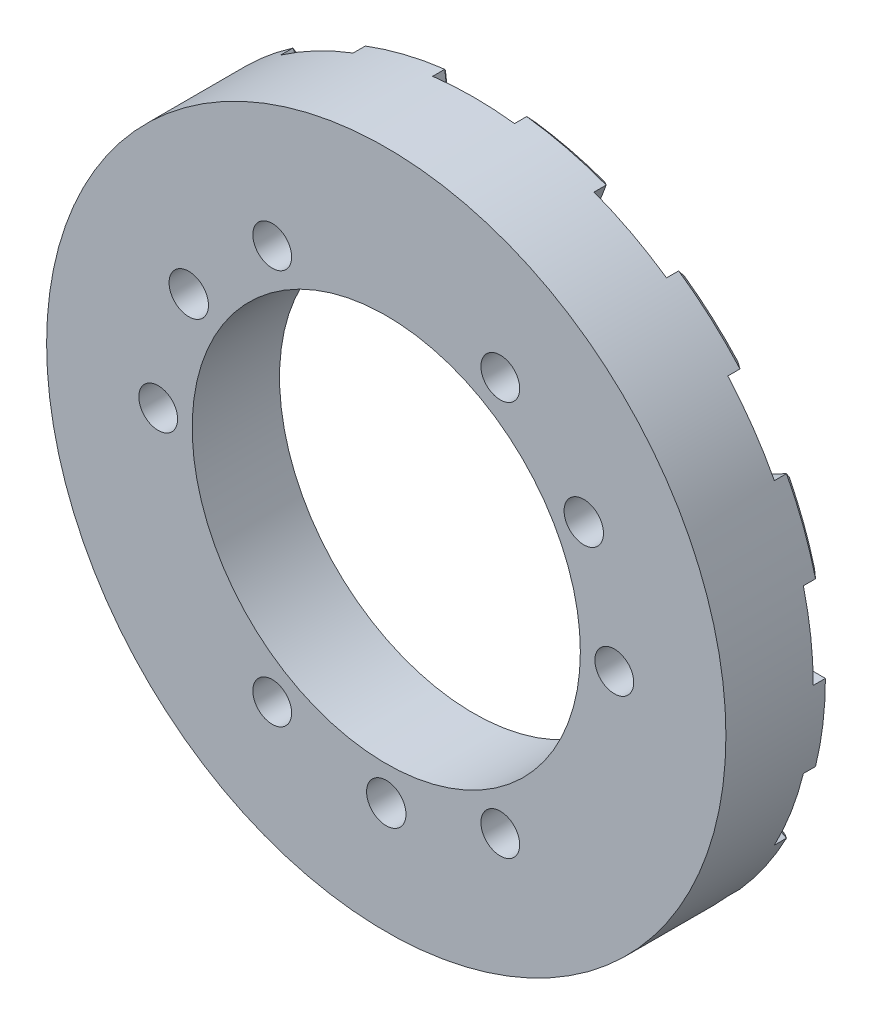
from build123d import *

# Parameters (mm, degrees)
SKETCH_1_R               = 70
SKETCH_1_R_2             = 40
EXTRUDE_1_DEPTH          = 18
SKETCH_2_R               = 4
CUT_EXTRUDE_1_DEPTH      = 20
PATTERN_CIRCULAR_1_COUNT = 6
SKETCH_3_R               = 4.06
CUT_EXTRUDE_2_DEPTH      = 20
PATTERN_CIRCULAR_2_COUNT = 3
EXTRUDE_2_DEPTH          = 3.5
CHAMFER_1_SIZE           = 1


with BuildPart() as part:
    # 草图1 → 凸台-拉伸1 (new body)
    with BuildSketch(Plane.XY):
        Circle(SKETCH_1_R)
        Circle(SKETCH_1_R_2, mode=Mode.SUBTRACT)
    extrude(amount=EXTRUDE_1_DEPTH)

    # 草图2 → 切除-拉伸1 (cut)
    with BuildSketch(Plane.XY.offset(18)):
        with Locations((47, 0)):
            Circle(SKETCH_2_R)
    cut_extrude_1 = extrude(amount=-CUT_EXTRUDE_1_DEPTH, mode=Mode.SUBTRACT)

    # 阵列(圆周)1: 切除-拉伸1 ×6 about axis
    pattern_circular_1_axis = Axis((0, 0, 0), (0, 0, 1))
    for i in range(1, PATTERN_CIRCULAR_1_COUNT):
        add(cut_extrude_1.rotate(pattern_circular_1_axis, i * 360 / PATTERN_CIRCULAR_1_COUNT), mode=Mode.SUBTRACT)

    # 草图3 → 切除-拉伸2 (cut)
    with BuildSketch(Plane.XY.offset(18)):
        with Locations((40.703193978, 23.5)):
            Circle(SKETCH_3_R)
    cut_extrude_2 = extrude(amount=-CUT_EXTRUDE_2_DEPTH, mode=Mode.SUBTRACT)

    # 阵列(圆周)2: 切除-拉伸2 ×3 about axis
    pattern_circular_2_axis = Axis((0, 0, 0), (0, 0, 1))
    for i in range(1, PATTERN_CIRCULAR_2_COUNT):
        add(cut_extrude_2.rotate(pattern_circular_2_axis, i * 360 / PATTERN_CIRCULAR_2_COUNT), mode=Mode.SUBTRACT)

    # 草图4 → 凸台-拉伸2 (add)
    with BuildSketch(Plane(origin=(0, 0, 0), x_dir=(-1, 0, 0), z_dir=(0, 0, -1))):
        with BuildLine():
            Line((60, 0), (70, 0))
            ThreePointArc((70, 0), (69.489621187, -8.437567618), (67.96592722, -16.7520965))
            Line((67.96592722, -16.7520965), (58.256509046, -14.358939857))
            ThreePointArc((58.256509046, -14.358939857), (59.562532446, -7.232200815), (60, 0))
        make_face()
        with BuildLine():
            Line((58.256509046, 14.358939857), (67.96592722, 16.7520965))
            ThreePointArc((67.96592722, 16.7520965), (65.451136988, 24.822342093), (61.981921796, 32.530622043))
            Line((61.981921796, 32.530622043), (53.127361539, 27.883390323))
            ThreePointArc((53.127361539, 27.883390323), (56.100974561, 21.276293223), (58.256509046, 14.358939857))
        make_face()
        with BuildLine():
            Line((44.91064489, 39.787359494), (52.395752372, 46.418586077))
            ThreePointArc((52.395752372, 46.418586077), (46.418586077, 52.395752372), (39.764532271, 57.608870613))
            Line((39.764532271, 57.608870613), (34.083884804, 49.379031954))
            ThreePointArc((34.083884804, 49.379031954), (39.787359494, 44.91064489), (44.91064489, 39.787359494))
        make_face()
        with BuildLine():
            Line((21.276293223, 56.100974561), (24.822342093, 65.451136988))
            ThreePointArc((24.822342093, 65.451136988), (16.7520965, 67.96592722), (8.437567618, 69.489621187))
            Line((8.437567618, 69.489621187), (7.232200815, 59.562532446))
            ThreePointArc((7.232200815, 59.562532446), (14.358939857, 58.256509046), (21.276293223, 56.100974561))
        make_face()
        with BuildLine():
            Line((-7.232200815, 59.562532446), (-8.437567618, 69.489621187))
            ThreePointArc((-8.437567618, 69.489621187), (-16.7520965, 67.96592722), (-24.822342093, 65.451136988))
            Line((-24.822342093, 65.451136988), (-21.276293223, 56.100974561))
            ThreePointArc((-21.276293223, 56.100974561), (-14.358939857, 58.256509046), (-7.232200815, 59.562532446))
        make_face()
        with BuildLine():
            Line((-34.083884804, 49.379031954), (-39.764532271, 57.608870613))
            ThreePointArc((-39.764532271, 57.608870613), (-46.418586077, 52.395752372), (-52.395752372, 46.418586077))
            Line((-52.395752372, 46.418586077), (-44.91064489, 39.787359494))
            ThreePointArc((-44.91064489, 39.787359494), (-39.787359494, 44.91064489), (-34.083884804, 49.379031954))
        make_face()
        with BuildLine():
            Line((-53.127361539, 27.883390323), (-61.981921796, 32.530622043))
            ThreePointArc((-61.981921796, 32.530622043), (-65.451136988, 24.822342093), (-67.96592722, 16.7520965))
            Line((-67.96592722, 16.7520965), (-58.256509046, 14.358939857))
            ThreePointArc((-58.256509046, 14.358939857), (-56.100974561, 21.276293223), (-53.127361539, 27.883390323))
        make_face()
        with BuildLine():
            Line((-60, 0), (-70, 0))
            ThreePointArc((-70, 0), (-69.489621187, -8.437567618), (-67.96592722, -16.7520965))
            Line((-67.96592722, -16.7520965), (-58.256509046, -14.358939857))
            ThreePointArc((-58.256509046, -14.358939857), (-59.562532446, -7.232200815), (-60, 0))
        make_face()
        with BuildLine():
            Line((-53.127361539, -27.883390323), (-61.981921796, -32.530622043))
            ThreePointArc((-61.981921796, -32.530622043), (-57.608870613, -39.764532271), (-52.395752372, -46.418586077))
            Line((-52.395752372, -46.418586077), (-44.91064489, -39.787359494))
            ThreePointArc((-44.91064489, -39.787359494), (-49.379031954, -34.083884804), (-53.127361539, -27.883390323))
        make_face()
        with BuildLine():
            Line((-34.083884804, -49.379031954), (-39.764532271, -57.608870613))
            ThreePointArc((-39.764532271, -57.608870613), (-32.530622043, -61.981921796), (-24.822342093, -65.451136988))
            Line((-24.822342093, -65.451136988), (-21.276293223, -56.100974561))
            ThreePointArc((-21.276293223, -56.100974561), (-27.883390323, -53.127361539), (-34.083884804, -49.379031954))
        make_face()
        with BuildLine():
            Line((-7.232200815, -59.562532446), (-8.437567618, -69.489621187))
            ThreePointArc((-8.437567618, -69.489621187), (0, -70), (8.437567618, -69.489621187))
            Line((8.437567618, -69.489621187), (7.232200815, -59.562532446))
            ThreePointArc((7.232200815, -59.562532446), (0, -60), (-7.232200815, -59.562532446))
        make_face()
        with BuildLine():
            Line((21.276293223, -56.100974561), (24.822342093, -65.451136988))
            ThreePointArc((24.822342093, -65.451136988), (32.530622043, -61.981921796), (39.764532271, -57.608870613))
            Line((39.764532271, -57.608870613), (34.083884804, -49.379031954))
            ThreePointArc((34.083884804, -49.379031954), (27.883390323, -53.127361539), (21.276293223, -56.100974561))
        make_face()
        with BuildLine():
            Line((44.91064489, -39.787359494), (52.395752372, -46.418586077))
            ThreePointArc((52.395752372, -46.418586077), (57.608870613, -39.764532271), (61.981921796, -32.530622043))
            Line((61.981921796, -32.530622043), (53.127361539, -27.883390323))
            ThreePointArc((53.127361539, -27.883390323), (49.379031954, -34.083884804), (44.91064489, -39.787359494))
        make_face()
    extrude(amount=EXTRUDE_2_DEPTH)

    # 倒角1
    chamfer_1_edges = [part.edges().sort_by_distance(p)[0] for p in [
        (-23.049317658, -60.776055775, -3.5),
        (-27.883390323, -53.127361539, -3.5),
        (-36.924208538, -53.493951283, -3.5),
        (-32.530622043, -61.981921796, -3.5),
        (7.834884217, -64.526076816, -3.5),
        (0, -60, -3.5),
        (-7.834884217, -64.526076816, -3.5),
        (0, -70, -3.5),
        (36.924208538, -53.493951283, -3.5),
        (27.883390323, -53.127361539, -3.5),
        (23.049317658, -60.776055775, -3.5),
        (32.530622043, -61.981921796, -3.5),
        (57.554641667, -30.207006183, -3.5),
        (49.379031954, -34.083884804, -3.5),
        (48.653198631, -43.102972786, -3.5),
        (57.608870613, -39.764532271, -3.5),
        (65, 0, -3.5),
        (59.562532446, -7.232200815, -3.5),
        (63.111218133, -15.555518179, -3.5),
        (69.489621187, -8.437567618, -3.5),
        (57.554641667, 30.207006183, -3.5),
        (56.100974561, 21.276293223, -3.5),
        (63.111218133, 15.555518179, -3.5),
        (65.451136988, 24.822342093, -3.5),
        (36.924208538, 53.493951283, -3.5),
        (39.787359494, 44.91064489, -3.5),
        (48.653198631, 43.102972786, -3.5),
        (46.418586077, 52.395752372, -3.5),
        (7.834884217, 64.526076816, -3.5),
        (14.358939857, 58.256509046, -3.5),
        (23.049317658, 60.776055775, -3.5),
        (16.7520965, 67.96592722, -3.5),
        (-23.049317658, 60.776055775, -3.5),
        (-14.358939857, 58.256509046, -3.5),
        (-7.834884217, 64.526076816, -3.5),
        (-16.7520965, 67.96592722, -3.5),
        (-48.653198631, 43.102972786, -3.5),
        (-39.787359494, 44.91064489, -3.5),
        (-36.924208538, 53.493951283, -3.5),
        (-46.418586077, 52.395752372, -3.5),
        (-63.111218133, 15.555518179, -3.5),
        (-56.100974561, 21.276293223, -3.5),
        (-57.554641667, 30.207006183, -3.5),
        (-65.451136988, 24.822342093, -3.5),
        (-63.111218133, -15.555518179, -3.5),
        (-59.562532446, -7.232200815, -3.5),
        (-65, 0, -3.5),
        (-69.489621187, -8.437567618, -3.5),
        (-48.653198631, -43.102972786, -3.5),
        (-49.379031954, -34.083884804, -3.5),
        (-57.554641667, -30.207006183, -3.5),
        (-57.608870613, -39.764532271, -3.5),
    ]]
    chamfer(chamfer_1_edges, length=CHAMFER_1_SIZE)


solid = part.part
